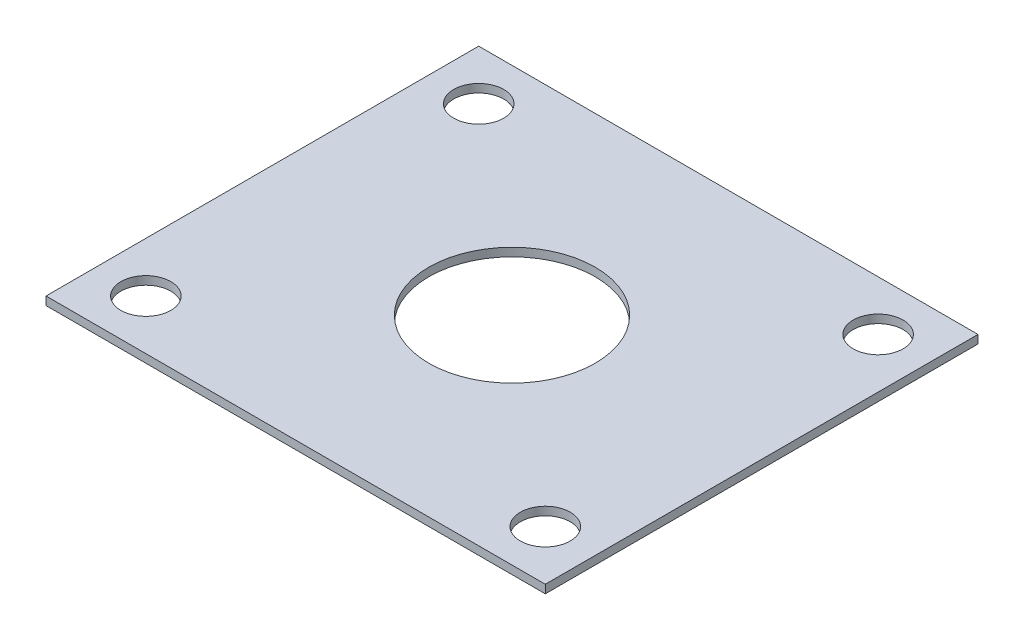
from build123d import *

# Parameters (mm, degrees)
SKETCH1_W           = 38.1
SKETCH1_H           = 33.02
BOSS_EXTRUDE1_DEPTH = 0.635
SKETCH2_R           = 1.905
CUT_EXTRUDE1_DEPTH  = 0.635
SKETCH3_R           = 6.35
CUT_EXTRUDE2_DEPTH  = 0.635


with BuildPart() as part:
    # Sketch1 → Boss-Extrude1 (new body)
    with BuildSketch(Plane(origin=(0, 0, 0), x_dir=(1, 0, 0), z_dir=(0, 1, 0))):
        with Locations((-19.05, 16.51)):
            Rectangle(SKETCH1_W, SKETCH1_H)
    extrude(amount=BOSS_EXTRUDE1_DEPTH)

    # Sketch2 → Cut-Extrude1 (cut)
    with BuildSketch(Plane(origin=(0, 0.635, 0), x_dir=(1, 0, 0), z_dir=(0, 1, 0))):
        with Locations((-34.29, 29.21)):
            Circle(SKETCH2_R)
        with Locations((-34.29, 3.81)):
            Circle(SKETCH2_R)
        with Locations((-3.81, 29.21)):
            Circle(SKETCH2_R)
        with Locations((-3.81, 3.81)):
            Circle(SKETCH2_R)
    extrude(amount=-CUT_EXTRUDE1_DEPTH, mode=Mode.SUBTRACT)

    # Sketch3 → Cut-Extrude2 (cut)
    with BuildSketch(Plane(origin=(0, 0.635, 0), x_dir=(1, 0, 0), z_dir=(0, 1, 0))):
        with Locations((-19.05, 16.51)):
            Circle(SKETCH3_R)
    extrude(amount=-CUT_EXTRUDE2_DEPTH, mode=Mode.SUBTRACT)


solid = part.part
